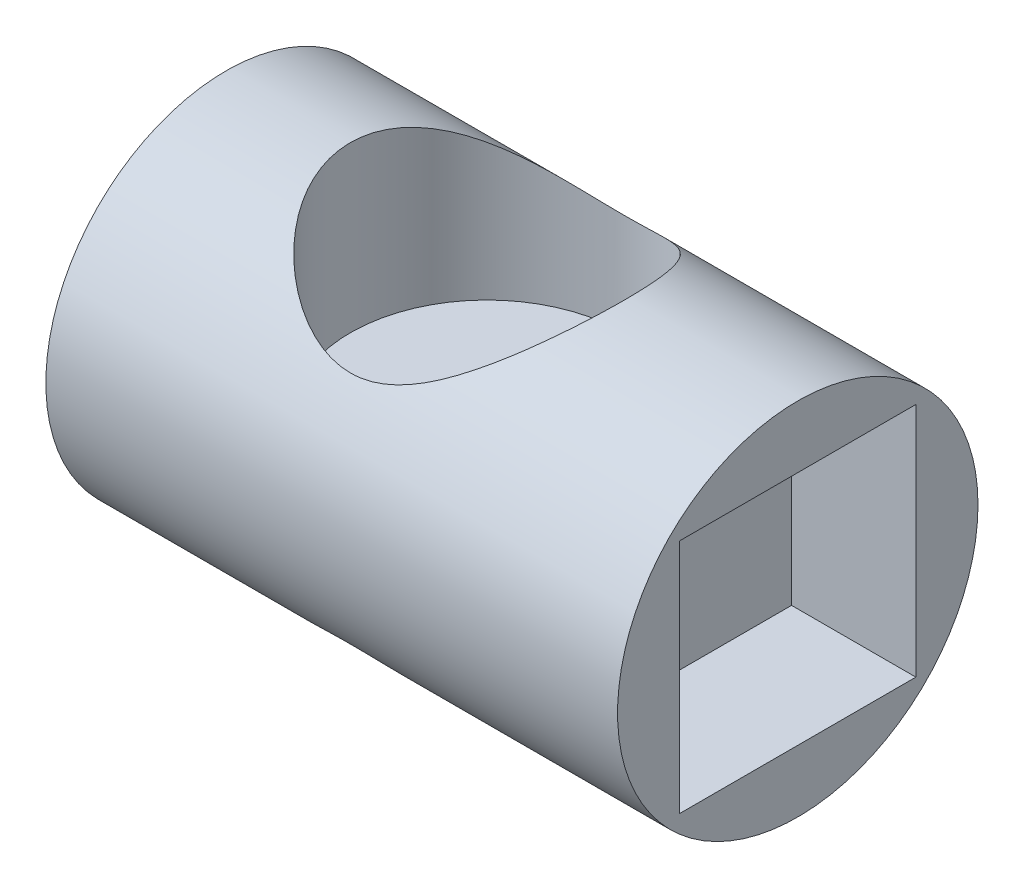
from build123d import *

# Parameters (mm, degrees)
CROQUIS1_R                 = 14.5
SALIENTE_EXTRUIR1_DEPTH    = 46
CROQUIS2_R                 = 4
CORTAR_EXTRUIR1_DEPTH      = 8
CROQUIS3_R                 = 11
CORTAR_EXTRUIR2_DEPTH      = 15.5
CORTAR_EXTRUIR2_DEPTH_BACK = 15.5
CROQUIS4_W                 = 19
CROQUIS4_H                 = 19
CORTAR_EXTRUIR3_DEPTH      = 10
CROQUIS5_W                 = 19
CROQUIS5_H                 = 2.5
SALIENTE_EXTRUIR2_DEPTH    = 28
CROQUIS7_R                 = 11.15
SALIENTE_EXTRUIR3_DEPTH    = 2.5


with BuildPart() as part:
    # Croquis1 → Saliente-Extruir1 (new body)
    with BuildSketch(Plane(origin=(0, 0, 0), x_dir=(0, 0, -1), z_dir=(1, 0, 0))):
        Circle(CROQUIS1_R)
    extrude(amount=SALIENTE_EXTRUIR1_DEPTH)

    # Croquis2 → Cortar-Extruir1 (cut)
    with BuildSketch(Plane.ZY):
        Circle(CROQUIS2_R)
    extrude(amount=-CORTAR_EXTRUIR1_DEPTH, mode=Mode.SUBTRACT)

    # Croquis3 → Cortar-Extruir2 (cut, two sides)
    with BuildSketch(Plane(origin=(0, 0, 0), x_dir=(1, 0, 0), z_dir=(0, 1, 0))) as cortar_extruir2_sk:
        with Locations((21, 0)):
            Circle(CROQUIS3_R)
    extrude(amount=CORTAR_EXTRUIR2_DEPTH, mode=Mode.SUBTRACT)
    extrude(cortar_extruir2_sk.sketch, amount=-CORTAR_EXTRUIR2_DEPTH_BACK, mode=Mode.SUBTRACT)

    # Croquis4 → Cortar-Extruir3 (cut)
    with BuildSketch(Plane(origin=(46, 0, 0), x_dir=(0, 0, -1), z_dir=(1, 0, 0))):
        Rectangle(CROQUIS4_W, CROQUIS4_H)
    extrude(amount=-CORTAR_EXTRUIR3_DEPTH, mode=Mode.SUBTRACT)

    # Croquis5 → Saliente-Extruir2 (add)
    with BuildSketch(Plane(origin=(36, 0, 0), x_dir=(0, 0, -1), z_dir=(1, 0, 0))):
        Rectangle(CROQUIS5_W, CROQUIS5_H)
    extrude(amount=-SALIENTE_EXTRUIR2_DEPTH)

    # Croquis7 → Saliente-Extruir3 (add)
    with BuildSketch(Plane.XZ.offset(1.25)):
        with Locations((21, 0)):
            Circle(CROQUIS7_R)
    extrude(amount=-SALIENTE_EXTRUIR3_DEPTH)


solid = part.part
